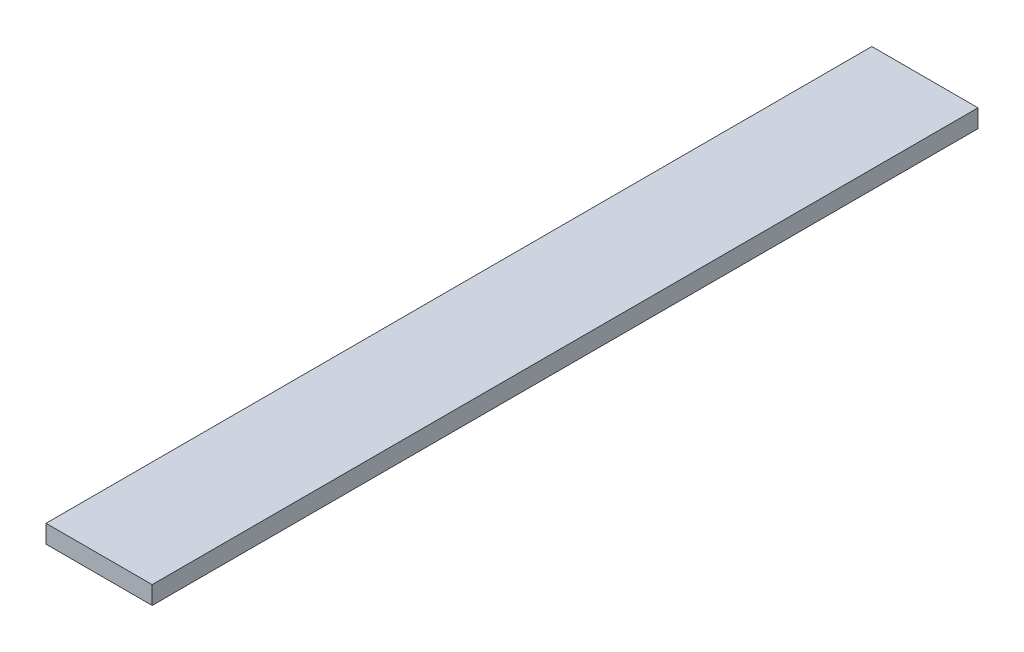
from build123d import *

# Parameters (mm, degrees)
CROQUIS1_W              = 135
CROQUIS1_H              = 23
SALIENTE_EXTRUIR1_DEPTH = 1050


with BuildPart() as part:
    # Croquis1 → Saliente-Extruir1 (new body)
    with BuildSketch(Plane.XY):
        with Locations((67.5, 11.5)):
            Rectangle(CROQUIS1_W, CROQUIS1_H)
    extrude(amount=-SALIENTE_EXTRUIR1_DEPTH)


solid = part.part
